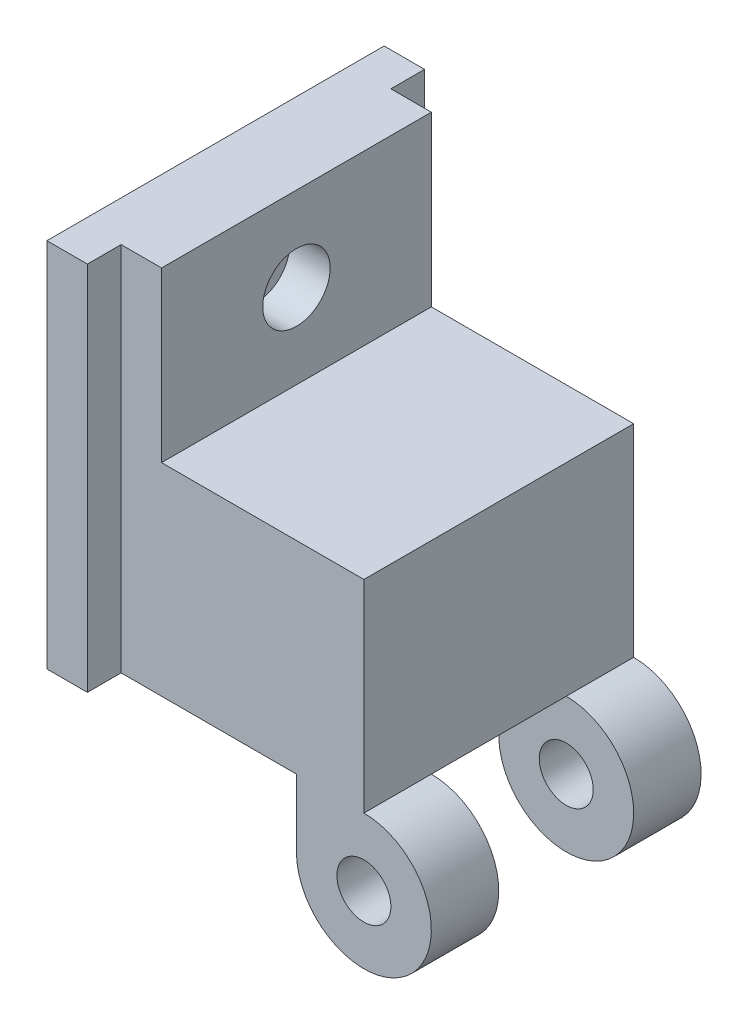
from build123d import *

# Parameters (mm, degrees)
SKETCH1_W                = 20
SKETCH1_H                = 15
BOSS_EXTRUDE1_DEPTH      = 15
SKETCH2_R                = 2
BOSS_EXTRUDE2_DEPTH      = 5
BOSS_EXTRUDE3_DEPTH      = 15
BOSS_EXTRUDE3_DEPTH_BACK = 12.5
SKETCH4_R                = 1.5
CUT_EXTRUDE1_DEPTH       = 6
SKETCH4_3_R              = 2.5
SKETCH4_3_R_2            = 1.5
CUT_EXTRUDE2_DEPTH       = 3


with BuildPart() as part:
    # Sketch1 → Boss-Extrude1 (new body)
    with BuildSketch(Plane(origin=(0, 0, 0), x_dir=(0, 0, -1), z_dir=(1, 0, 0))):
        Rectangle(SKETCH1_W, SKETCH1_H)
    extrude(amount=BOSS_EXTRUDE1_DEPTH)

    # Sketch2 → Boss-Extrude2 (add)
    with BuildSketch(Plane.XY.offset(10)):
        with BuildLine():
            Line((15, -7.5), (10.015567122, -7.5))
            Line((10.015567122, -7.5), (10.015567122, -12.105755295))
            ThreePointArc((10.015567122, -12.105755295), (18.393285758, -16.172276101), (15, -7.5))
        make_face()
        with Locations((15, -12.5)):
            Circle(SKETCH2_R, mode=Mode.SUBTRACT)
    boss_extrude2 = extrude(amount=-BOSS_EXTRUDE2_DEPTH)

    # Mirror1: Boss-Extrude2 across plane
    add(boss_extrude2.mirror(Plane.XY))

    # Sketch3 → Boss-Extrude3 (add, two sides)
    with BuildSketch(Plane.XZ.offset(-7.5)) as boss_extrude3_sk:
        Polygon((-3, 10), (-3, 12.5), (-6, 12.5), (-6, -12.5), (-3, -12.5), (-3, -10), (0, -10), (0, 10), align=None)
    extrude(amount=BOSS_EXTRUDE3_DEPTH)
    extrude(boss_extrude3_sk.sketch, amount=-BOSS_EXTRUDE3_DEPTH_BACK)

    # Sketch4 → Cut-Extrude1 (cut)
    with BuildSketch(Plane(origin=(0, 0, 0), x_dir=(0, 0, -1), z_dir=(1, 0, 0))):
        with Locations((0, 13.75)):
            Circle(SKETCH4_R)
    extrude(amount=-CUT_EXTRUDE1_DEPTH, mode=Mode.SUBTRACT)

    # Sketch4_3 → Cut-Extrude2 (cut)
    with BuildSketch(Plane(origin=(0, 0, 0), x_dir=(0, 0, -1), z_dir=(1, 0, 0))):
        with Locations((0, 13.75)):
            Circle(SKETCH4_3_R)
        with Locations((0, 13.75)):
            Circle(SKETCH4_3_R_2, mode=Mode.SUBTRACT)
    extrude(amount=-CUT_EXTRUDE2_DEPTH, mode=Mode.SUBTRACT)


solid = part.part
